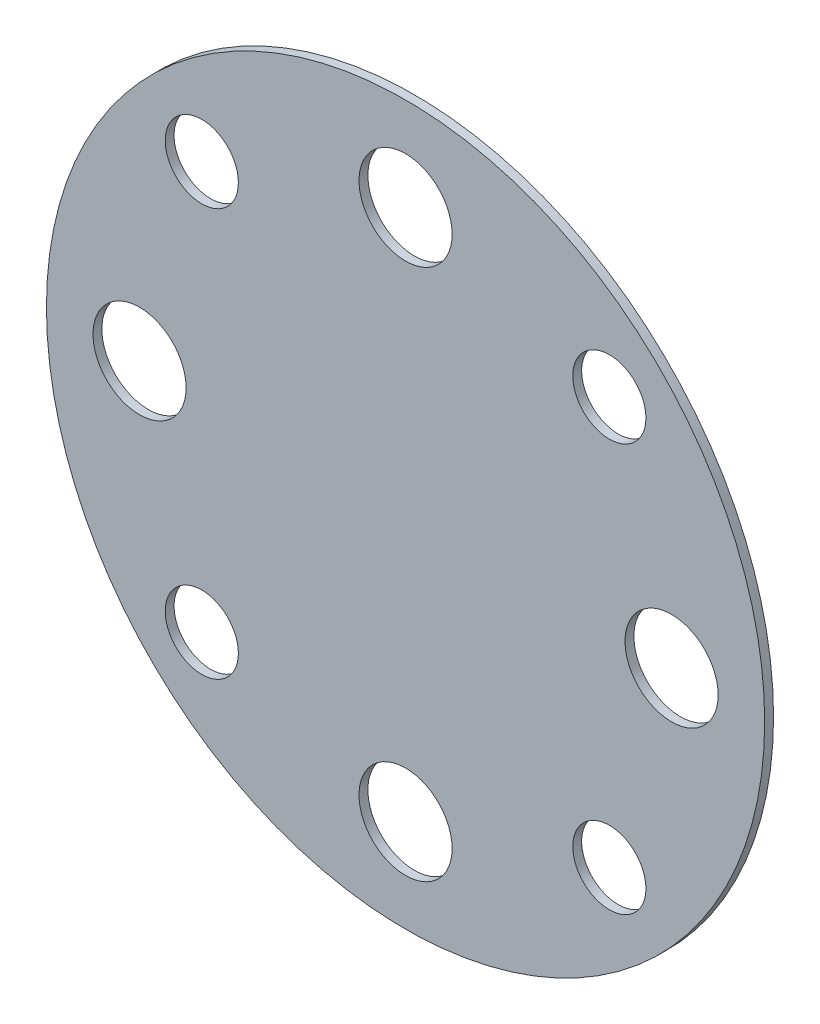
from build123d import *

# Parameters (mm, degrees)
SKETCH1_R           = 16.2
SKETCH1_R_2         = 2.1
SKETCH1_R_3         = 1.65
BOSS_EXTRUDE1_DEPTH = 0.4


with BuildPart() as part:
    # Sketch1 → Boss-Extrude1 (new body)
    with BuildSketch(Plane(origin=(0, 0, 0), x_dir=(0, 1, 0), z_dir=(0, 0, 1))):
        Circle(SKETCH1_R)
        with Locations((0, 12)):
            Circle(SKETCH1_R_2, mode=Mode.SUBTRACT)
        with Locations((9.192388155, 9.192388155)):
            Circle(SKETCH1_R_3, mode=Mode.SUBTRACT)
        with Locations((12, 0)):
            Circle(SKETCH1_R_2, mode=Mode.SUBTRACT)
        with Locations((9.192388155, -9.192388155)):
            Circle(SKETCH1_R_3, mode=Mode.SUBTRACT)
        with Locations((0, -12)):
            Circle(SKETCH1_R_2, mode=Mode.SUBTRACT)
        with Locations((-9.192388155, -9.192388155)):
            Circle(SKETCH1_R_3, mode=Mode.SUBTRACT)
        with Locations((-12, 0)):
            Circle(SKETCH1_R_2, mode=Mode.SUBTRACT)
        with Locations((-9.192388155, 9.192388155)):
            Circle(SKETCH1_R_3, mode=Mode.SUBTRACT)
    extrude(amount=BOSS_EXTRUDE1_DEPTH)


solid = part.part
